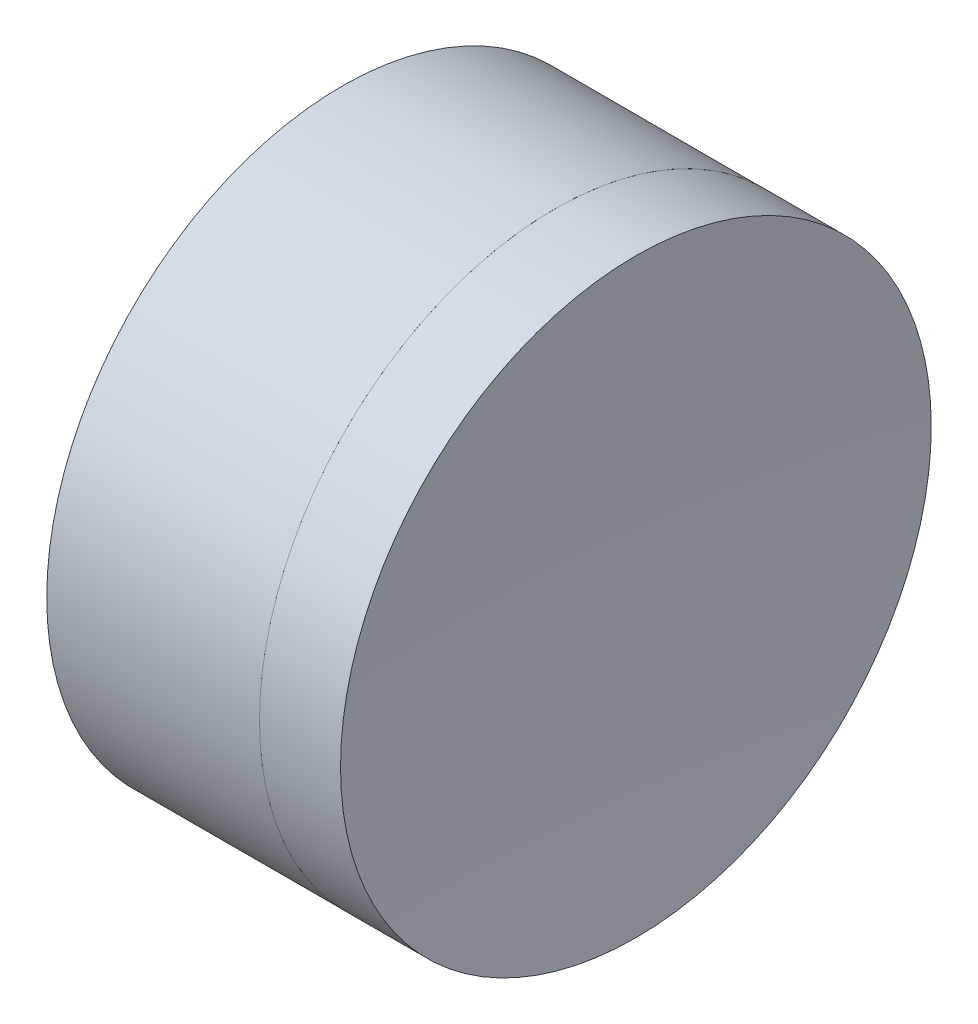
from build123d import *


with BuildPart() as part:
    # 草图1 one side → 旋转1 (revolve)
    with BuildSketch(Plane(origin=(0, 0, 0), x_dir=(1, 0, 0), z_dir=(0, 1, 0)), mode=Mode.PRIVATE) as revolve_1_sk:
        with BuildLine():
            Line((232.887812859, 6.35), (228.313932309, 6.35))
            ThreePointArc((228.313932309, 6.35), (229.497927293, 3.272614115), (229.900599442, 0))
            Line((229.900599442, 0), (231.400599442, 0))
            ThreePointArc((231.400599442, 0), (231.777366194, 3.260916426), (232.887812859, 6.35))
        make_face()
    revolve(revolve_1_sk.sketch.rotate(Axis((-0.816062176, 0, 0), (1, 0, 0)), 180), axis=Axis((-0.816062176, 0, 0), (1, 0, 0)))  # turned: the seam where the file's is


with BuildPart() as body_2:
    # 草图2 one side → 旋转3 (revolve)
    with BuildSketch(Plane(origin=(0, 0, 0), x_dir=(1, 0, 0), z_dir=(0, 1, 0)), mode=Mode.PRIVATE) as revolve_3_sk:
        with BuildLine():
            Line((234.630265234, 6.35), (232.887812859, 6.35))
            ThreePointArc((232.887812859, 6.35), (231.777366194, 3.260916426), (231.400599442, 0))
            Line((231.400599442, 0), (234.400599442, 0))
            ThreePointArc((234.400599442, 0), (234.458034654, 3.17707595), (234.630265234, 6.35))
        make_face()
    revolve(revolve_3_sk.sketch.rotate(Axis((228.313932309, 0, 0), (1, 0, 0)), 180), axis=Axis((228.313932309, 0, 0), (1, 0, 0)))  # turned: the seam where the file's is


solid = Compound([part.part, body_2.part])
